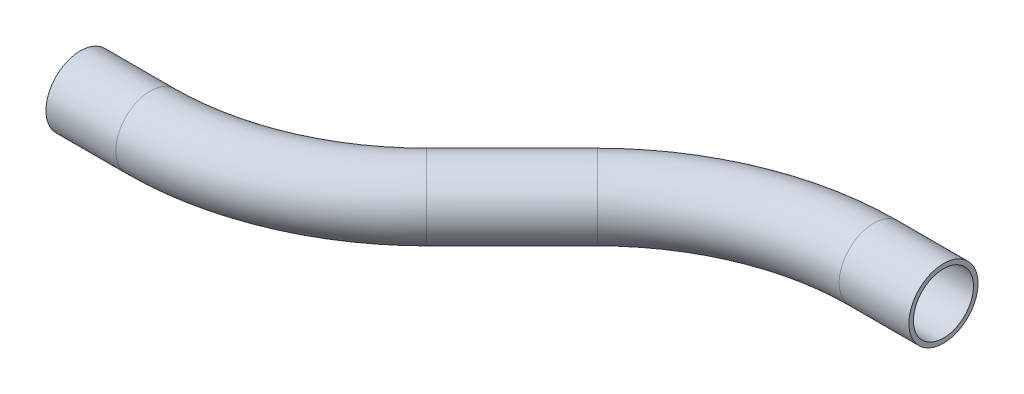
from build123d import *

# Parameters (mm, degrees)
SKETCH2_R   = 9.525
SKETCH2_R_2 = 8.2804


with BuildPart() as part:
    # Sweep1: sweep along a path in Sketch1
    with BuildLine(Plane(origin=(0, 0, 0), x_dir=(1, 0, 0), z_dir=(0, 1, 0))) as sweep1_path:
        Line((0, 0), (19.236926547, 0))
        ThreePointArc((19.236926547, 0), (48.397404093, 5.800379623), (73.118463274, 22.318463274))
        Line((73.118463274, 22.318463274), (96.637678138, 45.837678138))
        ThreePointArc((96.637678138, 45.837678138), (121.358737318, 62.355761789), (150.519214864, 68.156141412))
        Line((150.519214864, 68.156141412), (169.756141412, 68.156141412))
    # Sketch2 → Sweep1 (sweep)
    with BuildSketch(Plane(origin=(0, 0, 0), x_dir=(0, 0, -1), z_dir=(1, 0, 0))):
        Circle(SKETCH2_R)
        Circle(SKETCH2_R_2, mode=Mode.SUBTRACT)
    sweep(path=sweep1_path.line)


solid = part.part
